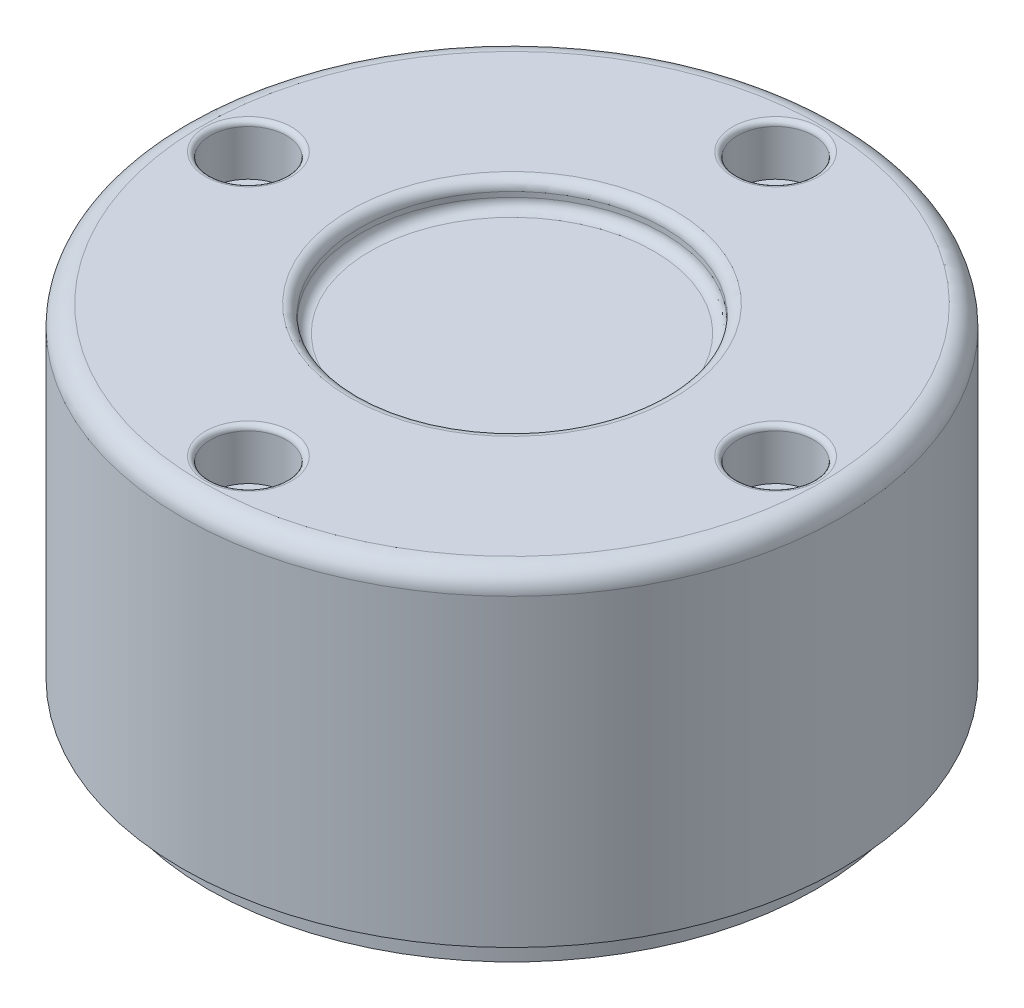
from build123d import *

# Parameters (mm, degrees)
SKETCH2_R           = 30
BOSS_EXTRUDE1_DEPTH = 3
SKETCH3_R           = 32.5
BOSS_EXTRUDE2_DEPTH = 32
SKETCH4_R           = 15
CUT_EXTRUDE1_DEPTH  = 2.5
SKETCH4_3_R         = 3.75
CUT_EXTRUDE2_DEPTH  = 5
FILLET1_R           = 1
FILLET2_R           = 1
FILLET3_R           = 2
FILLET4_R           = 0.5


with BuildPart() as part:
    # Sketch2 → Boss-Extrude1 (new body)
    with BuildSketch(Plane(origin=(0, 0, 0), x_dir=(1, 0, 0), z_dir=(0, 1, 0))):
        Circle(SKETCH2_R)
    extrude(amount=BOSS_EXTRUDE1_DEPTH)

    # Sketch3 → Boss-Extrude2 (add)
    with BuildSketch(Plane(origin=(0, 3, 0), x_dir=(1, 0, 0), z_dir=(0, 1, 0))):
        Circle(SKETCH3_R)
    extrude(amount=BOSS_EXTRUDE2_DEPTH)

    # Sketch4 → Cut-Extrude1 (cut)
    with BuildSketch(Plane(origin=(0, 35, 0), x_dir=(1, 0, 0), z_dir=(0, 1, 0))):
        Circle(SKETCH4_R)
    extrude(amount=-CUT_EXTRUDE1_DEPTH, mode=Mode.SUBTRACT)

    # Sketch4_3 → Cut-Extrude2 (cut)
    with BuildSketch(Plane(origin=(0, 35, 0), x_dir=(1, 0, 0), z_dir=(0, 1, 0))):
        with Locations((0, 26)):
            Circle(SKETCH4_3_R)
        with Locations((26, 0)):
            Circle(SKETCH4_3_R)
        with Locations((0, -26)):
            Circle(SKETCH4_3_R)
        with Locations((-26, 0)):
            Circle(SKETCH4_3_R)
    extrude(amount=-CUT_EXTRUDE2_DEPTH, mode=Mode.SUBTRACT)

    # Fillet1
    fillet1_edges = [part.edges().sort_by_distance(p)[0] for p in [
        (-15, 32.5, 0),
    ]]
    fillet(fillet1_edges, radius=FILLET1_R)

    # Fillet2
    fillet2_edges = [part.edges().sort_by_distance(p)[0] for p in [
        (-15, 35, 0),
    ]]
    fillet(fillet2_edges, radius=FILLET2_R)

    # Fillet3
    fillet3_edges = [part.edges().sort_by_distance(p)[0] for p in [
        (-32.5, 35, 0),
    ]]
    fillet(fillet3_edges, radius=FILLET3_R)

    # Fillet4
    fillet4_edges = [part.edges().sort_by_distance(p)[0] for p in [
        (-29.75, 35, 0),
        (-3.75, 35, -26),
        (22.25, 35, 0),
        (-3.75, 35, 26),
    ]]
    fillet(fillet4_edges, radius=FILLET4_R)


solid = part.part
